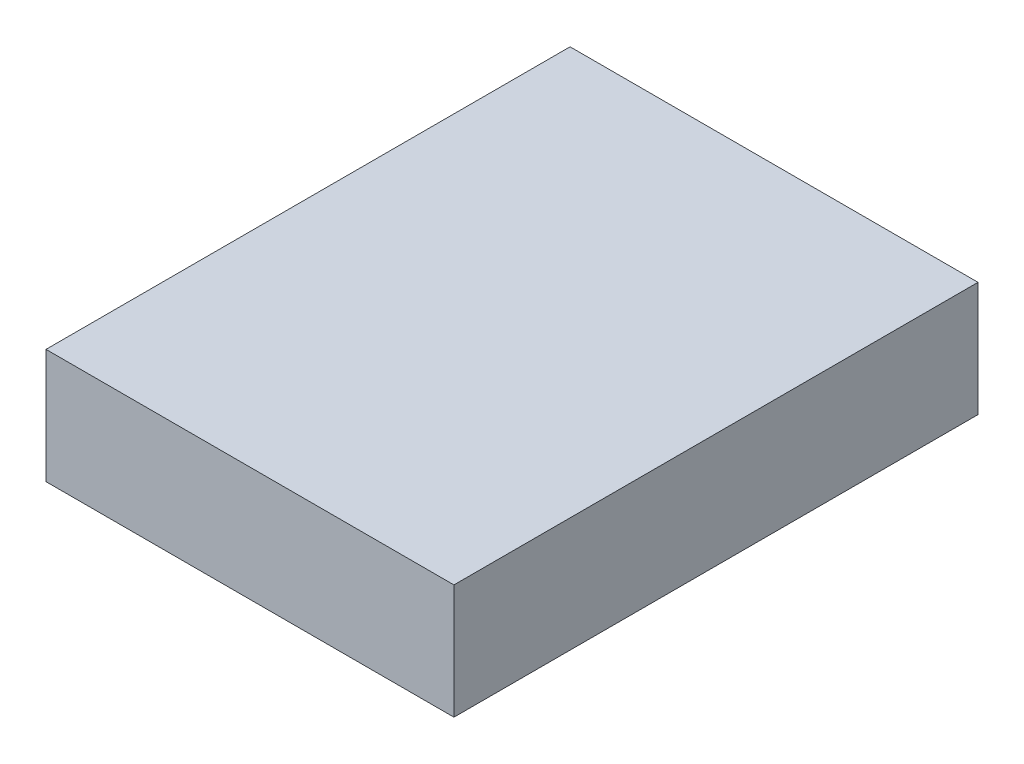
from build123d import *

# Parameters (mm, degrees)
SKETCH1_W           = 53.4
SKETCH1_H           = 68.6
BOSS_EXTRUDE1_DEPTH = 15


with BuildPart() as part:
    # Sketch1 → Boss-Extrude1 (new body)
    with BuildSketch(Plane(origin=(0, 0, 0), x_dir=(1, 0, 0), z_dir=(0, 1, 0))):
        Rectangle(SKETCH1_W, SKETCH1_H)
    extrude(amount=BOSS_EXTRUDE1_DEPTH)


solid = part.part
